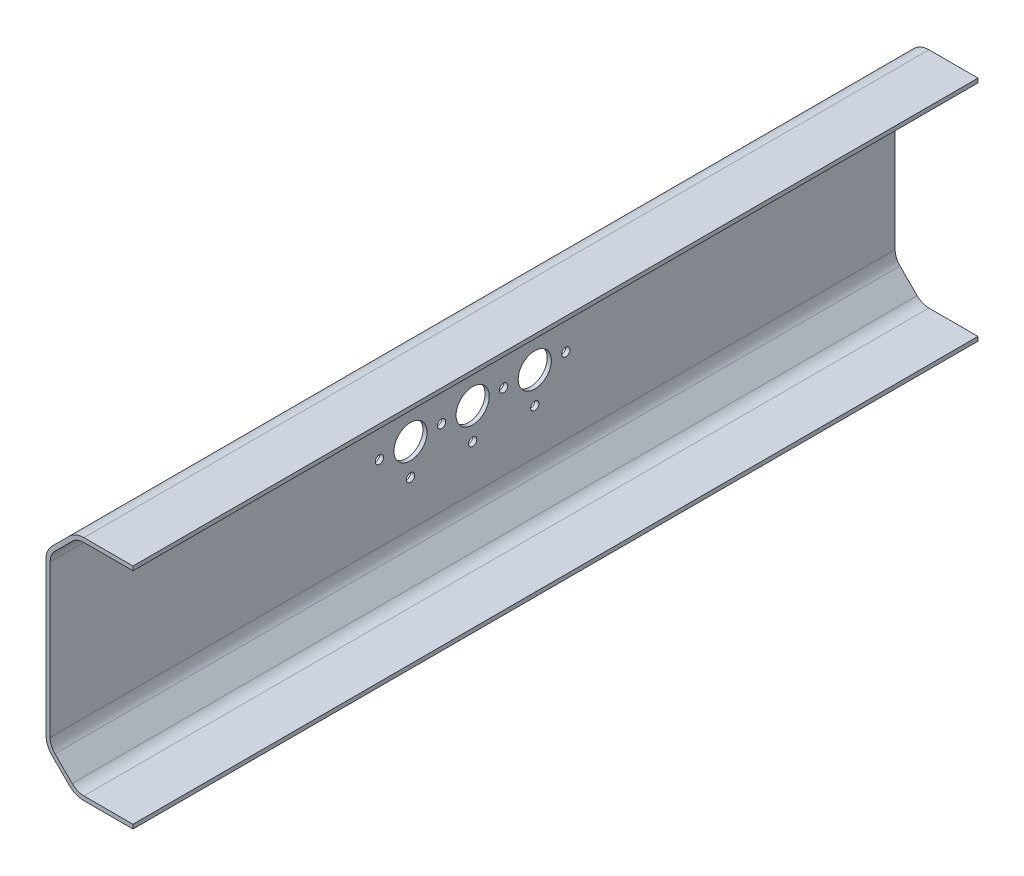
from build123d import *

# Parameters (mm, degrees)
BOSS_EXTRU_1_DEPTH      = 204
ESQUISSE2_R             = 4
ESQUISSE2_R_2           = 1
ENL_V_MAT_EXTRU_1_DEPTH = 22


with BuildPart() as part:
    # Esquisse1 → Boss.-Extru.1 (new body)
    with BuildSketch(Plane.XY):
        with BuildLine():
            Line((-1.464466094, 1.464466094), (-5.606601718, 5.606601718))
            ThreePointArc((-5.606601718, 5.606601718), (-6.690465474, 7.228718462), (-7.071067812, 9.142135624))
            Line((-7.071067812, 9.142135624), (-7.071067812, 45.857864376))
            ThreePointArc((-7.071067812, 45.857864376), (-6.690465474, 47.771281538), (-5.606601718, 49.393398282))
            Line((-5.606601718, 49.393398282), (-1.464466094, 53.535533906))
            ThreePointArc((-1.464466094, 53.535533906), (0.15765065, 54.619397663), (2.071067812, 55))
            Line((2.071067812, 55), (13.928932188, 55))
            Line((13.928932188, 55), (13.928932188, 54))
            Line((13.928932188, 54), (2.071067812, 54))
            ThreePointArc((2.071067812, 54), (0.540334082, 53.69551813), (-0.757359313, 52.828427125))
            Line((-0.757359313, 52.828427125), (-4.899494937, 48.686291501))
            ThreePointArc((-4.899494937, 48.686291501), (-5.766585942, 47.388598106), (-6.071067812, 45.857864376))
            Line((-6.071067812, 45.857864376), (-6.071067812, 9.142135624))
            ThreePointArc((-6.071067812, 9.142135624), (-5.766585942, 7.611401894), (-4.899494937, 6.313708499))
            Line((-4.899494937, 6.313708499), (-0.757359313, 2.171572875))
            ThreePointArc((-0.757359313, 2.171572875), (0.540334082, 1.30448187), (2.071067812, 1))
            Line((2.071067812, 1), (13.928932188, 1))
            Line((13.928932188, 1), (13.928932188, 0))
            Line((13.928932188, 0), (2.071067812, 0))
            ThreePointArc((2.071067812, 0), (0.15765065, 0.380602337), (-1.464466094, 1.464466094))
        make_face()
    extrude(amount=BOSS_EXTRU_1_DEPTH)

    # Esquisse2 → Enlèv. mat.-Extru.1 (cut, through all)
    with BuildSketch(Plane.ZY.offset(7.071067812)):
        with Locations((102, 27.5)):
            Circle(ESQUISSE2_R)
        with Locations((102, 35)):
            Circle(ESQUISSE2_R_2)
        with Locations((109.5, 27.5)):
            Circle(ESQUISSE2_R_2)
        with Locations((102, 20)):
            Circle(ESQUISSE2_R_2)
        with Locations((94.5, 27.5)):
            Circle(ESQUISSE2_R_2)
        with Locations((117, 27.5)):
            Circle(ESQUISSE2_R)
        with Locations((117, 35)):
            Circle(ESQUISSE2_R_2)
        with Locations((124.5, 27.5)):
            Circle(ESQUISSE2_R_2)
        with Locations((117, 20)):
            Circle(ESQUISSE2_R_2)
        with Locations((87, 27.5)):
            Circle(ESQUISSE2_R)
        with Locations((87, 35)):
            Circle(ESQUISSE2_R_2)
        with Locations((87, 20)):
            Circle(ESQUISSE2_R_2)
        with Locations((79.5, 27.5)):
            Circle(ESQUISSE2_R_2)
    extrude(amount=-ENL_V_MAT_EXTRU_1_DEPTH, mode=Mode.SUBTRACT)


solid = part.part
